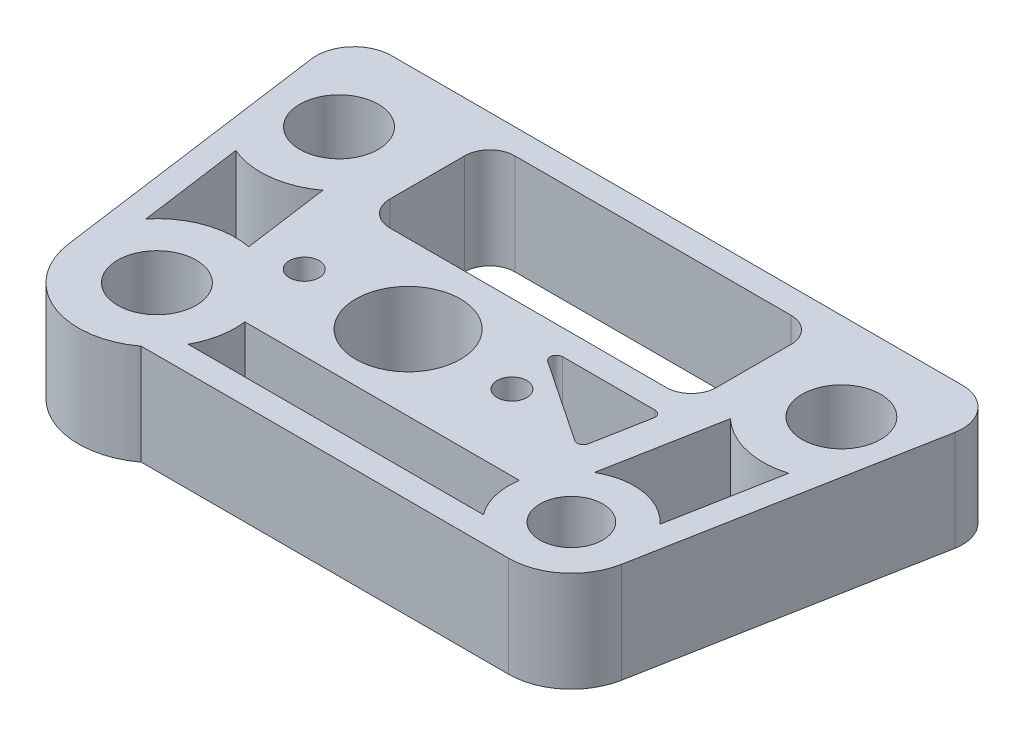
from build123d import *

# Parameters (mm, degrees)
SKETCH4_R           = 3.96875
SKETCH4_R_2         = 5.2959
SKETCH4_R_3         = 1.5
SKETCH4_R_4         = 3.175
BOSS_EXTRUDE2_DEPTH = 10.16
FILLET1_R           = 3.81


with BuildPart() as part:
    # Sketch4 → Boss-Extrude2 (new body)
    with BuildSketch(Plane(origin=(0, 0, 0), x_dir=(1, 0, 0), z_dir=(0, 1, 0))):
        with BuildLine():
            Line((54.2925, 31.75), (-12.3825, 31.75))
            Line((-12.3825, 31.75), (-7.863361559, -1.082336008))
            ThreePointArc((-7.863361559, -1.082336008), (-3.056289676, -7.325503373), (4.7625, -6.35))
            Line((4.7625, -6.35), (41.91, -6.35))
            ThreePointArc((41.91, -6.35), (45.967580476, -4.884520517), (48.152310263, -1.164501002))
            Line((48.152310263, -1.164501002), (54.2925, 31.75))
        make_face()
        Circle(SKETCH4_R, mode=Mode.SUBTRACT)
        with Locations((46.355, 22.86)):
            Circle(SKETCH4_R, mode=Mode.SUBTRACT)
        with Locations((-4.445, 22.86)):
            Circle(SKETCH4_R, mode=Mode.SUBTRACT)
        with Locations((16.764, 8.636)):
            Circle(SKETCH4_R_2, mode=Mode.SUBTRACT)
        with Locations((27.264, 8.636)):
            Circle(SKETCH4_R_3, mode=Mode.SUBTRACT)
        with Locations((6.264, 8.636)):
            Circle(SKETCH4_R_3, mode=Mode.SUBTRACT)
        with Locations((41.91, 0)):
            Circle(SKETCH4_R_4, mode=Mode.SUBTRACT)
        with BuildLine():
            Line((34.925, 29.21), (6.985, 29.21))
            ThreePointArc((6.985, 29.21), (5.188948776, 28.466051224), (4.445, 26.67))
            Line((4.445, 26.67), (4.445, 19.1135))
            ThreePointArc((4.445, 19.1135), (5.188948776, 17.317448776), (6.985, 16.5735))
            Line((6.985, 16.5735), (34.925, 16.5735))
            ThreePointArc((34.925, 16.5735), (36.721051224, 17.317448776), (37.465, 19.1135))
            Line((37.465, 19.1135), (37.465, 26.67))
            ThreePointArc((37.465, 26.67), (36.721051224, 28.466051224), (34.925, 29.21))
        make_face(mode=Mode.SUBTRACT)
        with BuildLine():
            Line((46.58698696, 4.295147609), (48.631735848, 15.256028661))
            ThreePointArc((48.631735848, 15.256028661), (44.519378774, 15.137668683), (40.900146495, 17.093850549))
            Line((40.900146495, 17.093850549), (38.737442476, 5.500670755))
            ThreePointArc((38.737442476, 5.500670755), (42.873923491, 6.276412312), (46.58698696, 4.295147609))
        make_face(mode=Mode.SUBTRACT)
        with BuildLine():
            Line((36.83, -3.81), (6.963318623, -3.81))
            ThreePointArc((6.963318623, -3.81), (7.800370345, -1.469057088), (7.872207457, 1.016))
            Line((7.872207457, 1.016), (35.641806959, 1.016))
            ThreePointArc((35.641806959, 1.016), (35.744131016, -1.518077625), (36.83, -3.81))
        make_face(mode=Mode.SUBTRACT)
        with BuildLine():
            Line((-6.14066773, 5.029523445), (-7.591897143, 15.572960504))
            ThreePointArc((-7.591897143, 15.572960504), (-3.525796009, 14.975903966), (0.293891225, 16.492361803))
            Line((0.293891225, 16.492361803), (1.490851578, 7.796234208))
            ThreePointArc((1.490851578, 7.796234208), (-2.705340953, 7.462240721), (-6.14066773, 5.029523445))
        make_face(mode=Mode.SUBTRACT)
        with BuildLine():
            Line((35.921478098, 7.718896983), (36.959282513, 13.2820499))
            ThreePointArc((36.959282513, 13.2820499), (36.823503538, 13.804258048), (36.335051487, 14.0335))
            Line((36.335051487, 14.0335), (27.003423807, 14.0335))
            ThreePointArc((27.003423807, 14.0335), (26.395931126, 13.583371961), (26.649696678, 12.871146117))
            Line((26.649696678, 12.871146117), (34.943519943, 7.307993201))
            ThreePointArc((34.943519943, 7.307993201), (35.543221805, 7.249922938), (35.921478098, 7.718896983))
        make_face(mode=Mode.SUBTRACT)
    extrude(amount=BOSS_EXTRUDE2_DEPTH)

    # Fillet1
    fillet1_edges = [part.edges().sort_by_distance(p)[0] for p in [
        (-12.3825, 5.08, -31.75),
        (54.2925, 5.08, -31.75),
    ]]
    fillet(fillet1_edges, radius=FILLET1_R)


solid = part.part
